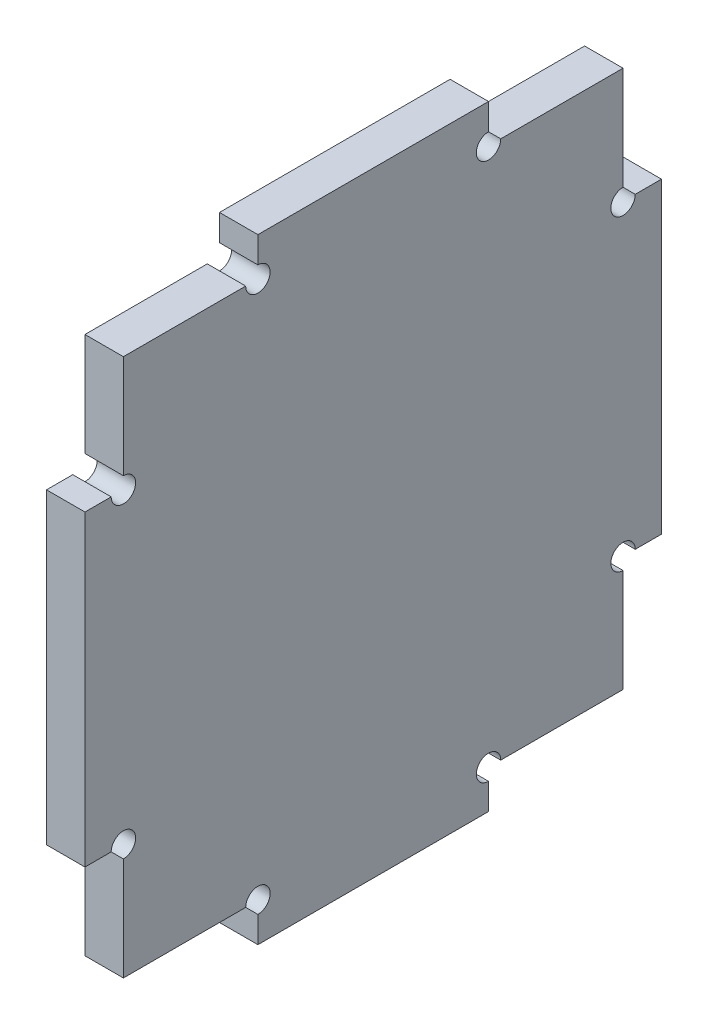
from build123d import *

# Parameters (mm, degrees)
SKETCH1_W                                = 75
SKETCH1_H                                = 80
BOSS_EXTRUDE1_DEPTH                      = 5
CUT_EXTRUDE1_START                       = -6
CUT_EXTRUDE1_DEPTH                       = 7
MIRROR1_START                            = -6
MIRROR1_AT_THE_SECOND_PLANE_COPY_1_DEPTH = 7
SKETCH4_R                                = 1.5875
CUT_EXTRUDE2_DEPTH                       = 6


with BuildPart() as part:
    # Sketch1 → Boss-Extrude1 (new body)
    with BuildSketch(Plane(origin=(0, 0, 0), x_dir=(0, 0, -1), z_dir=(1, 0, 0))):
        Rectangle(SKETCH1_W, SKETCH1_H)
    extrude(amount=BOSS_EXTRUDE1_DEPTH)

    # Sketch3 → Cut-Extrude1 (cut)
    with BuildSketch(Plane(origin=(5, 0, 0), x_dir=(0, 0, -1), z_dir=(1, 0, 0)).offset(CUT_EXTRUDE1_START)):
        Polygon((-37.5, 20), (-32.5, 20), (-32.5, 35), (-15, 35), (-15, 40), (-37.5, 40), align=None)
    cut_extrude1 = extrude(amount=CUT_EXTRUDE1_DEPTH, mode=Mode.SUBTRACT)

    # Mirror1: Cut-Extrude1 across plane
    add(cut_extrude1.mirror(Plane.XY), mode=Mode.SUBTRACT)

    # Mirror1 at the second plane: Cut-Extrude1 across plane
    add(cut_extrude1.mirror(Plane.ZX), mode=Mode.SUBTRACT)

    # Mirror1 at the second plane copy 1 sketc → Mirror1 at the second plane copy 1 (cut)
    with BuildSketch(Plane(origin=(5, 0, 0), x_dir=(0, 0, 1), z_dir=(1, 0, 0)).offset(MIRROR1_START)):
        Polygon((-37.5, 20), (-32.5, 20), (-32.5, 35), (-15, 35), (-15, 40), (-37.5, 40), align=None)
    extrude(amount=MIRROR1_AT_THE_SECOND_PLANE_COPY_1_DEPTH, mode=Mode.SUBTRACT)

    # Sketch4 → Cut-Extrude2 (cut, through all)
    with BuildSketch(Plane(origin=(5, 0, 0), x_dir=(0, 0, -1), z_dir=(1, 0, 0))):
        with Locations((-15, 35)):
            Circle(SKETCH4_R)
        with Locations((15, 35)):
            Circle(SKETCH4_R)
        with Locations((32.5, 20)):
            Circle(SKETCH4_R)
        with Locations((32.5, -20)):
            Circle(SKETCH4_R)
        with Locations((15, -35)):
            Circle(SKETCH4_R)
        with Locations((-15, -35)):
            Circle(SKETCH4_R)
        with Locations((-32.5, -20)):
            Circle(SKETCH4_R)
        with Locations((-32.5, 20)):
            Circle(SKETCH4_R)
    extrude(amount=-CUT_EXTRUDE2_DEPTH, mode=Mode.SUBTRACT)


solid = part.part
